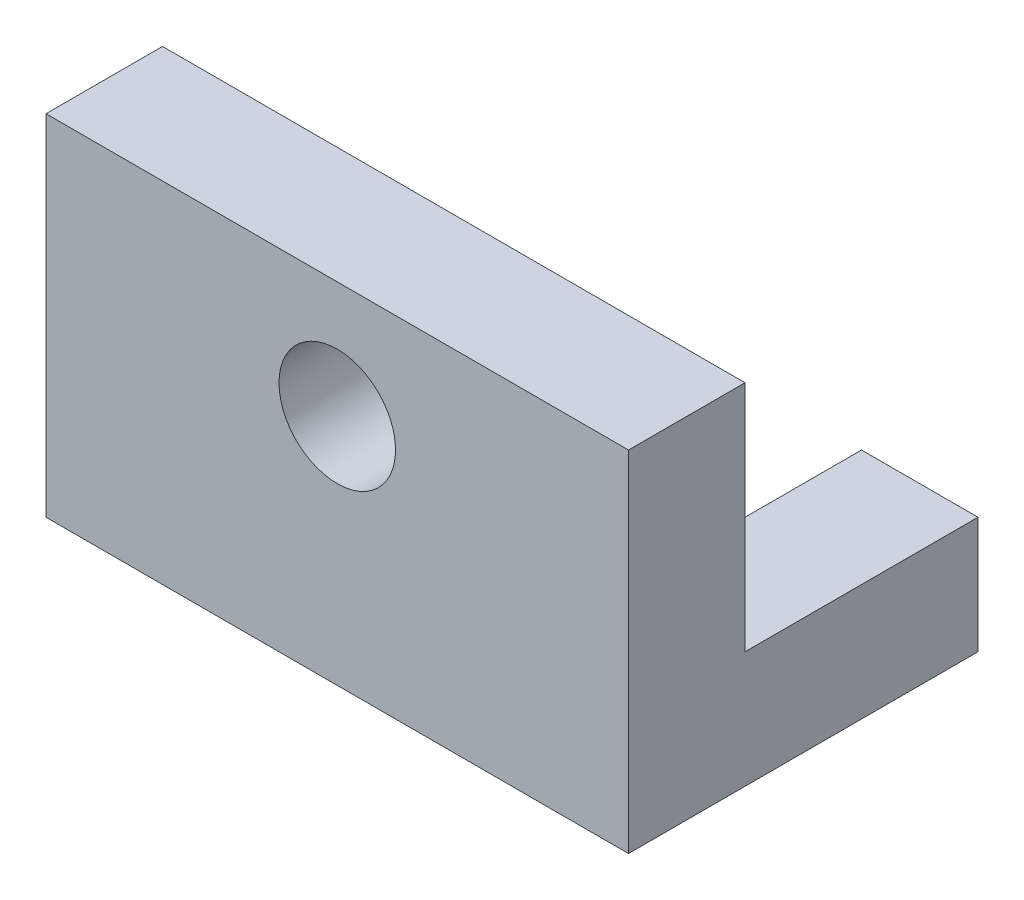
from build123d import *

# Parameters (mm, degrees)
BOSS_EXTRUDE1_DEPTH = 50
SKETCH2_R           = 10
CUT_EXTRUDE1_DEPTH  = 21
CUT_EXTRUDE2_REACH  = 22
SKETCH3_W           = 60
SKETCH3_H           = 20


with BuildPart() as part:
    # Sketch1 → Boss-Extrude1 (new body, symmetric)
    with BuildSketch(Plane(origin=(0, 0, 0), x_dir=(0, 0, -1), z_dir=(1, 0, 0))):
        Polygon((0, 0), (60, 0), (60, 20), (20, 20), (20, 60), (0, 60), align=None)
    extrude(amount=BOSS_EXTRUDE1_DEPTH, both=True)

    # Sketch2 → Cut-Extrude1 (cut, through all)
    with BuildSketch(Plane(origin=(0, 0, -20), x_dir=(-1, 0, 0), z_dir=(0, 0, -1))):
        with Locations((0, 40)):
            Circle(SKETCH2_R)
    extrude(amount=-CUT_EXTRUDE1_DEPTH, mode=Mode.SUBTRACT)

    # Sketch3 → Cut-Extrude2 (cut, up to next)
    with BuildSketch(Plane(origin=(0, 20, 0), x_dir=(1, 0, 0), z_dir=(0, 1, 0)), mode=Mode.PRIVATE) as cut_extrude2_sk1:
        with Locations((0, 50)):
            Rectangle(SKETCH3_W, SKETCH3_H)
    cut_extrude2_tool1 = extrude(cut_extrude2_sk1.sketch, amount=-CUT_EXTRUDE2_REACH, mode=Mode.PRIVATE) & part.part
    add(cut_extrude2_tool1.solids().sort_by_distance((0, 20, -50))[0], mode=Mode.SUBTRACT)


solid = part.part
